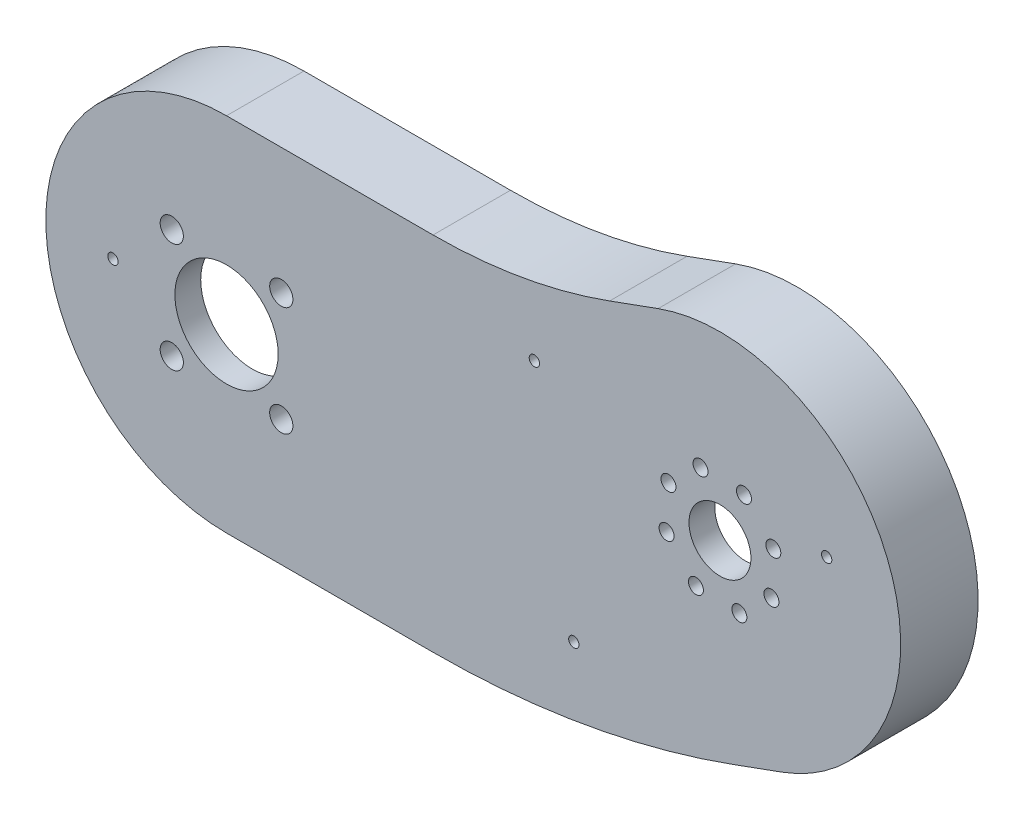
from build123d import *

# Parameters (mm, degrees)
EXTRUDE_1_DEPTH     = 20
CHAMFER_1_SIZE      = 10
CUT_EXTRUDE_1_DEPTH = 15
CUT_EXTRUDE_2_REACH = 22
SKETCH_3_R          = 1.45
SKETCH_3_R_2        = 6
CUT_EXTRUDE_3_REACH = 22
SKETCH_4_R          = 10
SKETCH_4_R_2        = 2.25
SKETCH_5_R          = 4
EXTRUDE_2_DEPTH     = 5
FILLET_1_R          = 5
CUT_EXTRUDE_4_REACH = 12
SKETCH_6_R          = 1
FILLET_2_R          = 5
EXTRUDE_3_DEPTH     = 13
CUT_EXTRUDE_5_DEPTH = 5


with BuildPart() as part:
    # 스케치1 → 보스-돌출1 (new body)
    with BuildSketch(Plane.XY):
        with BuildLine():
            Line((0, 35), (40, 35))
            ThreePointArc((40, 35), (57.364817767, 36.519224699), (74.202014333, 41.030737921))
            Line((74.202014333, 41.030737921), (83.59894054, 44.450939355))
            ThreePointArc((83.59894054, 44.450939355), (128.458887284, 23.532402644), (107.540350573, -21.3275441))
            Line((107.540350573, -21.3275441), (98.143424365, -24.747745534))
            ThreePointArc((98.143424365, -24.747745534), (69.520190203, -32.417318012), (40, -35))
            Line((40, -35), (0, -35))
            ThreePointArc((0, -35), (-35, 0), (0, 35))
        make_face()
    extrude(amount=EXTRUDE_1_DEPTH)

    # 모따기1
    chamfer_1_edges = [part.edges().sort_by_distance(p)[0] for p in [
        (20, -35, 0),
        (-35, 0, 0),
        (20, 35, 0),
        (57.364817767, 36.519224699, 0),
        (78.900477436, 42.740838638, 0),
        (128.458887284, 23.532402644, 0),
        (102.841887469, -23.037644817, 0),
        (69.520190203, -32.417318012, 0),
    ]]
    chamfer(chamfer_1_edges, length=CHAMFER_1_SIZE)

    # 스케치2 → 컷-돌출1 (cut)
    with BuildSketch(Plane(origin=(0, 0, 0), x_dir=(-1, 0, 0), z_dir=(0, 0, -1))):
        with BuildLine():
            Line((-40, -25), (0, -25))
            ThreePointArc((0, -25), (25, 0), (0, 25))
            Line((0, 25), (-40, 25))
            ThreePointArc((-40, 25), (-59.101299543, 26.671147169), (-77.622215766, 31.633811714))
            Line((-77.622215766, 31.633811714), (-87.019141974, 35.054013147))
            ThreePointArc((-87.019141974, 35.054013147), (-119.061961076, 20.11220121), (-104.12014914, -11.930617892))
            Line((-104.12014914, -11.930617892), (-94.723222932, -15.350819326))
            ThreePointArc((-94.723222932, -15.350819326), (-67.783708427, -22.569240482), (-40, -25))
        make_face()
    extrude(amount=-CUT_EXTRUDE_1_DEPTH, mode=Mode.SUBTRACT)

    # 스케치3 → 컷-돌출2 (cut, up to next)
    with BuildSketch(Plane.XY.offset(20), mode=Mode.PRIVATE) as cut_extrude_2_sk1:
        with Locations((105.906264385, 15.323919204)):
            Circle(SKETCH_3_R)
    cut_extrude_2_tool1 = extrude(cut_extrude_2_sk1.sketch, amount=-CUT_EXTRUDE_2_REACH, mode=Mode.PRIVATE) & part.part
    add(cut_extrude_2_tool1.solids().sort_by_distance((105.906264, 15.323919, 20))[0], mode=Mode.SUBTRACT)
    # 스케치3 → 컷-돌출2 (cut, up to next)
    with BuildSketch(Plane.XY.offset(20), mode=Mode.PRIVATE) as cut_extrude_2_sk2:
        with Locations((95.569645557, 11.561697627)):
            Circle(SKETCH_3_R_2)
    cut_extrude_2_tool2 = extrude(cut_extrude_2_sk2.sketch, amount=-CUT_EXTRUDE_2_REACH, mode=Mode.PRIVATE) & part.part
    add(cut_extrude_2_tool2.solids().sort_by_distance((95.569646, 11.561698, 20))[0], mode=Mode.SUBTRACT)
    # 스케치3 → 컷-돌출2 (cut, up to next)
    with BuildSketch(Plane.XY.offset(20), mode=Mode.PRIVATE) as cut_extrude_2_sk3:
        with Locations((91.80742398, 21.898316456)):
            Circle(SKETCH_3_R)
    cut_extrude_2_tool3 = extrude(cut_extrude_2_sk3.sketch, amount=-CUT_EXTRUDE_2_REACH, mode=Mode.PRIVATE) & part.part
    add(cut_extrude_2_tool3.solids().sort_by_distance((91.807424, 21.898316, 20))[0], mode=Mode.SUBTRACT)
    # 스케치3 → 컷-돌출2 (cut, up to next)
    with BuildSketch(Plane.XY.offset(20), mode=Mode.PRIVATE) as cut_extrude_2_sk4:
        with Locations((85.233026728, 7.799476051)):
            Circle(SKETCH_3_R)
    cut_extrude_2_tool4 = extrude(cut_extrude_2_sk4.sketch, amount=-CUT_EXTRUDE_2_REACH, mode=Mode.PRIVATE) & part.part
    add(cut_extrude_2_tool4.solids().sort_by_distance((85.233027, 7.799476, 20))[0], mode=Mode.SUBTRACT)
    # 스케치3 → 컷-돌출2 (cut, up to next)
    with BuildSketch(Plane.XY.offset(20), mode=Mode.PRIVATE) as cut_extrude_2_sk5:
        with Locations((99.331867133, 1.225078799)):
            Circle(SKETCH_3_R)
    cut_extrude_2_tool5 = extrude(cut_extrude_2_sk5.sketch, amount=-CUT_EXTRUDE_2_REACH, mode=Mode.PRIVATE) & part.part
    add(cut_extrude_2_tool5.solids().sort_by_distance((99.331867, 1.225079, 20))[0], mode=Mode.SUBTRACT)
    # 스케치3 → 컷-돌출2 (cut, up to next)
    with BuildSketch(Plane.XY.offset(20), mode=Mode.PRIVATE) as cut_extrude_2_sk6:
        with Locations((85.600259899, 16.210498506)):
            Circle(SKETCH_3_R)
    cut_extrude_2_tool6 = extrude(cut_extrude_2_sk6.sketch, amount=-CUT_EXTRUDE_2_REACH, mode=Mode.PRIVATE) & part.part
    add(cut_extrude_2_tool6.solids().sort_by_distance((85.60026, 16.210499, 20))[0], mode=Mode.SUBTRACT)
    # 스케치3 → 컷-돌출2 (cut, up to next)
    with BuildSketch(Plane.XY.offset(20), mode=Mode.PRIVATE) as cut_extrude_2_sk7:
        with Locations((100.218446436, 21.531083285)):
            Circle(SKETCH_3_R)
    cut_extrude_2_tool7 = extrude(cut_extrude_2_sk7.sketch, amount=-CUT_EXTRUDE_2_REACH, mode=Mode.PRIVATE) & part.part
    add(cut_extrude_2_tool7.solids().sort_by_distance((100.218446, 21.531083, 20))[0], mode=Mode.SUBTRACT)
    # 스케치3 → 컷-돌출2 (cut, up to next)
    with BuildSketch(Plane.XY.offset(20), mode=Mode.PRIVATE) as cut_extrude_2_sk8:
        with Locations((105.539031214, 6.912896748)):
            Circle(SKETCH_3_R)
    cut_extrude_2_tool8 = extrude(cut_extrude_2_sk8.sketch, amount=-CUT_EXTRUDE_2_REACH, mode=Mode.PRIVATE) & part.part
    add(cut_extrude_2_tool8.solids().sort_by_distance((105.539031, 6.912897, 20))[0], mode=Mode.SUBTRACT)
    # 스케치3 → 컷-돌출2 (cut, up to next)
    with BuildSketch(Plane.XY.offset(20), mode=Mode.PRIVATE) as cut_extrude_2_sk9:
        with Locations((90.920844678, 1.59231197)):
            Circle(SKETCH_3_R)
    cut_extrude_2_tool9 = extrude(cut_extrude_2_sk9.sketch, amount=-CUT_EXTRUDE_2_REACH, mode=Mode.PRIVATE) & part.part
    add(cut_extrude_2_tool9.solids().sort_by_distance((90.920845, 1.592312, 20))[0], mode=Mode.SUBTRACT)

    # 스케치4 → 컷-돌출3 (cut, up to next)
    with BuildSketch(Plane.XY.offset(20), mode=Mode.PRIVATE) as cut_extrude_3_sk1:
        Circle(SKETCH_4_R)
    cut_extrude_3_tool1 = extrude(cut_extrude_3_sk1.sketch, amount=-CUT_EXTRUDE_3_REACH, mode=Mode.PRIVATE) & part.part
    add(cut_extrude_3_tool1.solids().sort_by_distance((0, 0, 20))[0], mode=Mode.SUBTRACT)
    # 스케치4 → 컷-돌출3 (cut, up to next)
    with BuildSketch(Plane.XY.offset(20), mode=Mode.PRIVATE) as cut_extrude_3_sk2:
        with Locations((10.606601718, -10.606601718)):
            Circle(SKETCH_4_R_2)
    cut_extrude_3_tool2 = extrude(cut_extrude_3_sk2.sketch, amount=-CUT_EXTRUDE_3_REACH, mode=Mode.PRIVATE) & part.part
    add(cut_extrude_3_tool2.solids().sort_by_distance((10.606602, -10.606602, 20))[0], mode=Mode.SUBTRACT)
    # 스케치4 → 컷-돌출3 (cut, up to next)
    with BuildSketch(Plane.XY.offset(20), mode=Mode.PRIVATE) as cut_extrude_3_sk3:
        with Locations((10.606601718, 10.606601718)):
            Circle(SKETCH_4_R_2)
    cut_extrude_3_tool3 = extrude(cut_extrude_3_sk3.sketch, amount=-CUT_EXTRUDE_3_REACH, mode=Mode.PRIVATE) & part.part
    add(cut_extrude_3_tool3.solids().sort_by_distance((10.606602, 10.606602, 20))[0], mode=Mode.SUBTRACT)
    # 스케치4 → 컷-돌출3 (cut, up to next)
    with BuildSketch(Plane.XY.offset(20), mode=Mode.PRIVATE) as cut_extrude_3_sk4:
        with Locations((-10.606601718, -10.606601718)):
            Circle(SKETCH_4_R_2)
    cut_extrude_3_tool4 = extrude(cut_extrude_3_sk4.sketch, amount=-CUT_EXTRUDE_3_REACH, mode=Mode.PRIVATE) & part.part
    add(cut_extrude_3_tool4.solids().sort_by_distance((-10.606602, -10.606602, 20))[0], mode=Mode.SUBTRACT)
    # 스케치4 → 컷-돌출3 (cut, up to next)
    with BuildSketch(Plane.XY.offset(20), mode=Mode.PRIVATE) as cut_extrude_3_sk5:
        with Locations((-10.606601718, 10.606601718)):
            Circle(SKETCH_4_R_2)
    cut_extrude_3_tool5 = extrude(cut_extrude_3_sk5.sketch, amount=-CUT_EXTRUDE_3_REACH, mode=Mode.PRIVATE) & part.part
    add(cut_extrude_3_tool5.solids().sort_by_distance((-10.606602, 10.606602, 20))[0], mode=Mode.SUBTRACT)

    # 스케치5 → 보스-돌출2 (add)
    with BuildSketch(Plane(origin=(0, 0, 15), x_dir=(-1, 0, 0), z_dir=(0, 0, -1))):
        with Locations((22, 0)):
            Circle(SKETCH_5_R)
        with Locations((-59.622244076, 23.71672391)):
            Circle(SKETCH_5_R)
        with Locations((-67.262763894, -19.614817223)):
            Circle(SKETCH_5_R)
        with Locations((-116.234543326, 19.109350842)):
            Circle(SKETCH_5_R)
    extrude(amount=EXTRUDE_2_DEPTH)

    # 필렛1
    fillet_1_edges = [part.edges().sort_by_distance(p)[0] for p in [
        (-24.840909091, 2.81588983, 12.5),
        (-24.840909091, -2.81588983, 12.5),
        (56.525365318, 26.248391731, 12.5),
        (61.666476802, 27.154908396, 12.5),
        (65.149596455, -23.011068594, 12.5),
        (70.410078123, -22.083503744, 12.5),
        (119.869013308, 17.438833572, 12.5),
        (117.936809755, 22.729059256, 12.5),
    ]]
    fillet(fillet_1_edges, radius=FILLET_1_R)

    # 스케치6 → 컷-돌출4 (cut, up to next)
    with BuildSketch(Plane(origin=(0, 0, 10), x_dir=(-1, 0, 0), z_dir=(0, 0, -1)), mode=Mode.PRIVATE) as cut_extrude_4_sk1:
        with Locations((-116.234543326, 19.109350842)):
            Circle(SKETCH_6_R)
    cut_extrude_4_tool1 = extrude(cut_extrude_4_sk1.sketch, amount=-CUT_EXTRUDE_4_REACH, mode=Mode.PRIVATE) & part.part
    add(cut_extrude_4_tool1.solids().sort_by_distance((116.234543, 19.109351, 10))[0], mode=Mode.SUBTRACT)
    # 스케치6 → 컷-돌출4 (cut, up to next)
    with BuildSketch(Plane(origin=(0, 0, 10), x_dir=(-1, 0, 0), z_dir=(0, 0, -1)), mode=Mode.PRIVATE) as cut_extrude_4_sk2:
        with Locations((-67.262763894, -19.614817223)):
            Circle(SKETCH_6_R)
    cut_extrude_4_tool2 = extrude(cut_extrude_4_sk2.sketch, amount=-CUT_EXTRUDE_4_REACH, mode=Mode.PRIVATE) & part.part
    add(cut_extrude_4_tool2.solids().sort_by_distance((67.262764, -19.614817, 10))[0], mode=Mode.SUBTRACT)
    # 스케치6 → 컷-돌출4 (cut, up to next)
    with BuildSketch(Plane(origin=(0, 0, 10), x_dir=(-1, 0, 0), z_dir=(0, 0, -1)), mode=Mode.PRIVATE) as cut_extrude_4_sk3:
        with Locations((-59.622244076, 23.71672391)):
            Circle(SKETCH_6_R)
    cut_extrude_4_tool3 = extrude(cut_extrude_4_sk3.sketch, amount=-CUT_EXTRUDE_4_REACH, mode=Mode.PRIVATE) & part.part
    add(cut_extrude_4_tool3.solids().sort_by_distance((59.622244, 23.716724, 10))[0], mode=Mode.SUBTRACT)
    # 스케치6 → 컷-돌출4 (cut, up to next)
    with BuildSketch(Plane(origin=(0, 0, 10), x_dir=(-1, 0, 0), z_dir=(0, 0, -1)), mode=Mode.PRIVATE) as cut_extrude_4_sk4:
        with Locations((22, 0)):
            Circle(SKETCH_6_R)
    cut_extrude_4_tool4 = extrude(cut_extrude_4_sk4.sketch, amount=-CUT_EXTRUDE_4_REACH, mode=Mode.PRIVATE) & part.part
    add(cut_extrude_4_tool4.solids().sort_by_distance((-22, 0, 10))[0], mode=Mode.SUBTRACT)

    # 필렛2
    fillet_2_edges = [part.edges().sort_by_distance(p)[0] for p in [
        (20, -35, 10),
        (69.520190203, -32.417318012, 10),
        (102.841887469, -23.037644817, 10),
        (128.458887284, 23.532402644, 10),
        (78.900477436, 42.740838638, 10),
        (57.364817767, 36.519224699, 10),
        (20, 35, 10),
        (-35, 0, 10),
    ]]
    fillet(fillet_2_edges, radius=FILLET_2_R)

    # 스케치7 → 보스-돌출3 (add)
    with BuildSketch(Plane.XY):
        with BuildLine():
            Line((98.143424365, -24.747745534), (107.540350573, -21.3275441))
            ThreePointArc((107.540350573, -21.3275441), (128.458887284, 23.532402644), (83.59894054, 44.450939355))
            Line((83.59894054, 44.450939355), (74.202014333, 41.030737921))
            ThreePointArc((74.202014333, 41.030737921), (57.364817767, 36.519224699), (40, 35))
            Line((40, 35), (0, 35))
            ThreePointArc((0, 35), (-35, 0), (0, -35))
            Line((0, -35), (40, -35))
            ThreePointArc((40, -35), (69.520190203, -32.417318012), (98.143424365, -24.747745534))
        make_face()
        with BuildLine():
            Line((94.723222932, -15.350819326), (104.12014914, -11.930617892))
            ThreePointArc((104.12014914, -11.930617892), (119.061961076, 20.11220121), (87.019141974, 35.054013147))
            Line((87.019141974, 35.054013147), (77.622215766, 31.633811714))
            ThreePointArc((77.622215766, 31.633811714), (59.101299543, 26.671147169), (40, 25))
            Line((40, 25), (0, 25))
            ThreePointArc((0, 25), (-25, 0), (0, -25))
            Line((0, -25), (40, -25))
            ThreePointArc((40, -25), (67.783708427, -22.569240482), (94.723222932, -15.350819326))
        make_face(mode=Mode.SUBTRACT)
    extrude(amount=EXTRUDE_3_DEPTH)

    # 스케치8 → 컷-돌출5 (cut)
    with BuildSketch(Plane(origin=(0, 0, 0), x_dir=(-1, 0, 0), z_dir=(0, 0, -1))):
        with BuildLine():
            Line((-74.202014333, 41.030737921), (-83.59894054, 44.450939355))
            ThreePointArc((-83.59894054, 44.450939355), (-128.458887284, 23.532402644), (-107.540350573, -21.3275441))
            Line((-107.540350573, -21.3275441), (-98.143424365, -24.747745534))
            ThreePointArc((-98.143424365, -24.747745534), (-69.520190203, -32.417318012), (-40, -35))
            Line((-40, -35), (0, -35))
            ThreePointArc((0, -35), (35, 0), (0, 35))
            Line((0, 35), (-40, 35))
            ThreePointArc((-40, 35), (-57.364817767, 36.519224699), (-74.202014333, 41.030737921))
        make_face()
        with BuildLine():
            Line((-104.12014914, -11.930617892), (-94.723222932, -15.350819326))
            ThreePointArc((-94.723222932, -15.350819326), (-67.783708427, -22.569240482), (-40, -25))
            Line((-40, -25), (0, -25))
            ThreePointArc((0, -25), (25, 0), (0, 25))
            Line((0, 25), (-40, 25))
            ThreePointArc((-40, 25), (-59.101299543, 26.671147169), (-77.622215766, 31.633811714))
            Line((-77.622215766, 31.633811714), (-87.019141974, 35.054013147))
            ThreePointArc((-87.019141974, 35.054013147), (-119.061961076, 20.11220121), (-104.12014914, -11.930617892))
        make_face(mode=Mode.SUBTRACT)
    extrude(amount=-CUT_EXTRUDE_5_DEPTH, mode=Mode.SUBTRACT)


solid = part.part
